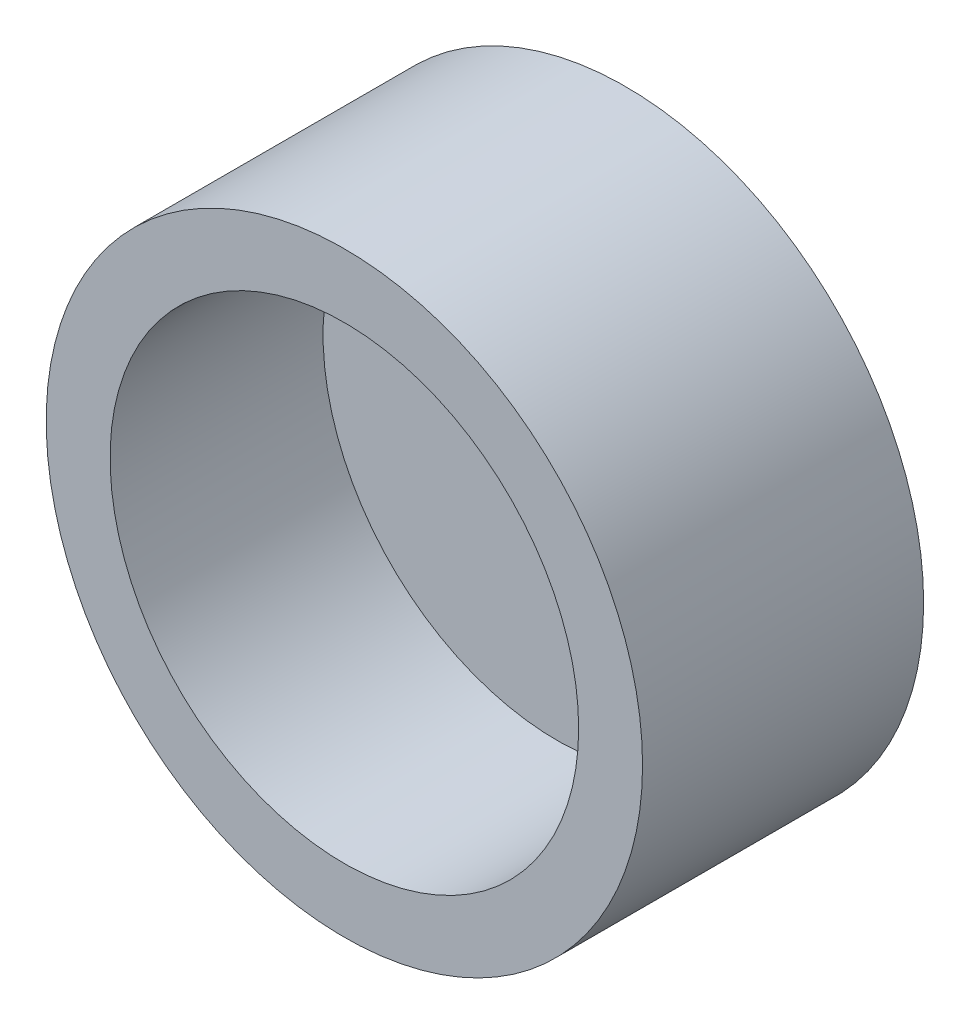
from build123d import *

# Parameters (mm, degrees)
SKETCH1_R           = 88.9
BOSS_EXTRUDE1_DEPTH = 83.8
SKETCH2_W           = 38.1
SKETCH2_H           = 15
BOSS_EXTRUDE2_DEPTH = 10
SKETCH4_R           = 2.5
CUT_EXTRUDE1_DEPTH  = 108.95
SKETCH5_R           = 2.5
CUT_EXTRUDE2_DEPTH  = 38.1
SKETCH6_R           = 69.85
CUT_EXTRUDE3_DEPTH  = 63.5


with BuildPart() as part:
    # Sketch1 → Boss-Extrude1 (new body)
    with BuildSketch(Plane.XY):
        Circle(SKETCH1_R)
    extrude(amount=BOSS_EXTRUDE1_DEPTH)

    # Sketch2 → Boss-Extrude2 (add)
    with BuildSketch(Plane(origin=(0, 0, 0), x_dir=(-1, 0, 0), z_dir=(0, 0, -1))):
        with Locations((0, 42.5)):
            Rectangle(SKETCH2_W, SKETCH2_H)
        with Locations((0, -42.5)):
            Rectangle(SKETCH2_W, SKETCH2_H)
    extrude(amount=BOSS_EXTRUDE2_DEPTH)

    # Sketch4 → Cut-Extrude1 (cut, through all)
    with BuildSketch(Plane(origin=(19.05, 0, 0), x_dir=(0, 0, -1), z_dir=(1, 0, 0))):
        with Locations((10, 42.5)):
            Circle(SKETCH4_R)
    extrude(amount=-CUT_EXTRUDE1_DEPTH, mode=Mode.SUBTRACT)

    # Sketch5 → Cut-Extrude2 (cut)
    with BuildSketch(Plane(origin=(19.05, 0, 0), x_dir=(0, 0, -1), z_dir=(1, 0, 0))):
        with Locations((10, -42.5)):
            Circle(SKETCH5_R)
    extrude(amount=-CUT_EXTRUDE2_DEPTH, mode=Mode.SUBTRACT)

    # Sketch6 → Cut-Extrude3 (cut)
    with BuildSketch(Plane.XY.offset(83.8)):
        Circle(SKETCH6_R)
    extrude(amount=-CUT_EXTRUDE3_DEPTH, mode=Mode.SUBTRACT)


solid = part.part
